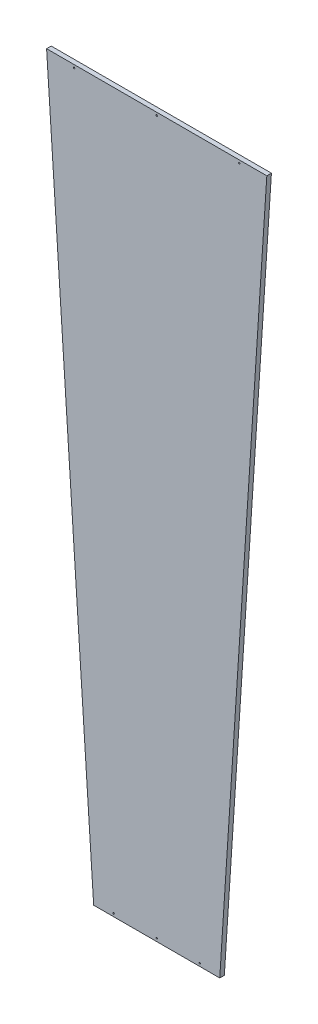
from build123d import *

# Parameters (mm, degrees)
EXTRUDE1_DEPTH = 0.16
SKETCH4_R      = 0.05
EXTRUDE3_DEPTH = 1.32


with BuildPart() as part:
    # Sketch1 → Extrude1 (new body, symmetric)
    with BuildSketch(Plane(origin=(0, 0, 0), x_dir=(-1, 0, 0), z_dir=(0, 0, -1))):
        Polygon((-4.387, 43.998003308), (4.387, 43.998003308), (7.663262056, 93.984102838), (-7.663262056, 93.984102838), align=None)
    extrude(amount=EXTRUDE1_DEPTH, both=True)

    # Sketch4 → Extrude3 (cut, through all)
    with BuildSketch(Plane.XY.offset(0.16)):
        with Locations((-3, 44.198003308)):
            Circle(SKETCH4_R)
        with Locations((0, 44.198003308)):
            Circle(SKETCH4_R)
        with Locations((3, 44.198003308)):
            Circle(SKETCH4_R)
        with Locations((-5.746391555, 93.784102838)):
            Circle(SKETCH4_R)
        with Locations((0, 93.784102838)):
            Circle(SKETCH4_R)
        with Locations((5.746391555, 93.784102838)):
            Circle(SKETCH4_R)
    extrude(amount=-EXTRUDE3_DEPTH, mode=Mode.SUBTRACT)


solid = part.part
